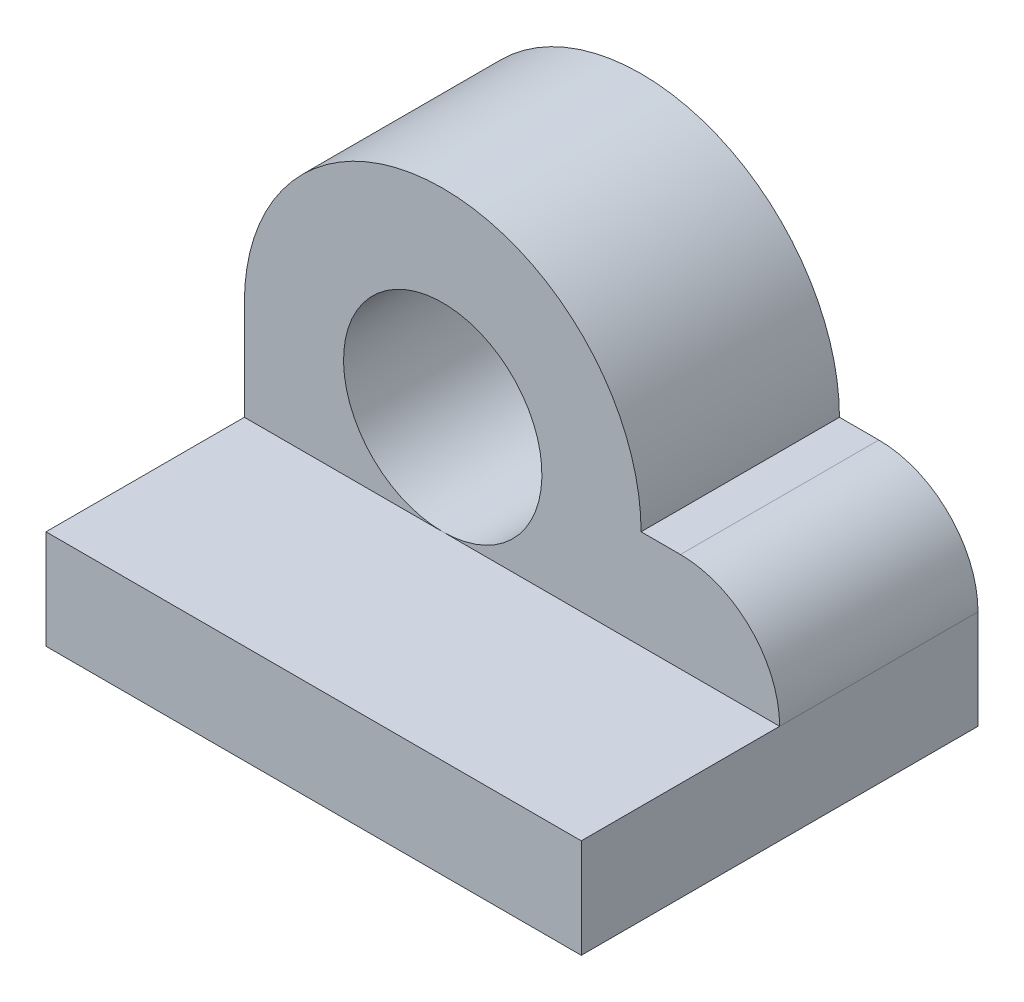
from build123d import *

# Parameters (mm, degrees)
SKETCH1_R           = 254
BOSS_EXTRUDE1_DEPTH = 508
BOSS_EXTRUDE2_DEPTH = 1016


with BuildPart() as part:
    # Sketch1 → Boss-Extrude1 (new body)
    with BuildSketch(Plane.XY):
        with BuildLine():
            Line((0, 0), (1370.792512001, 0))
            Line((1370.792512001, 0), (1370.792512001, 254))
            ThreePointArc((1370.792512001, 254), (1296.397634423, 433.605122421), (1116.792512001, 508))
            Line((1116.792512001, 508), (1016, 508))
            ThreePointArc((1016, 508), (508, 1016), (0, 508))
            Line((0, 508), (0, 0))
        make_face()
        with Locations((508, 508)):
            Circle(SKETCH1_R, mode=Mode.SUBTRACT)
    extrude(amount=BOSS_EXTRUDE1_DEPTH)

    # Sketch1_4 → Boss-Extrude2 (add)
    with BuildSketch(Plane.XY):
        Polygon((0, 254), (0, 0), (1370.792512001, 0), (1370.792512001, 254), (508, 254), align=None)
    extrude(amount=BOSS_EXTRUDE2_DEPTH)


solid = part.part
